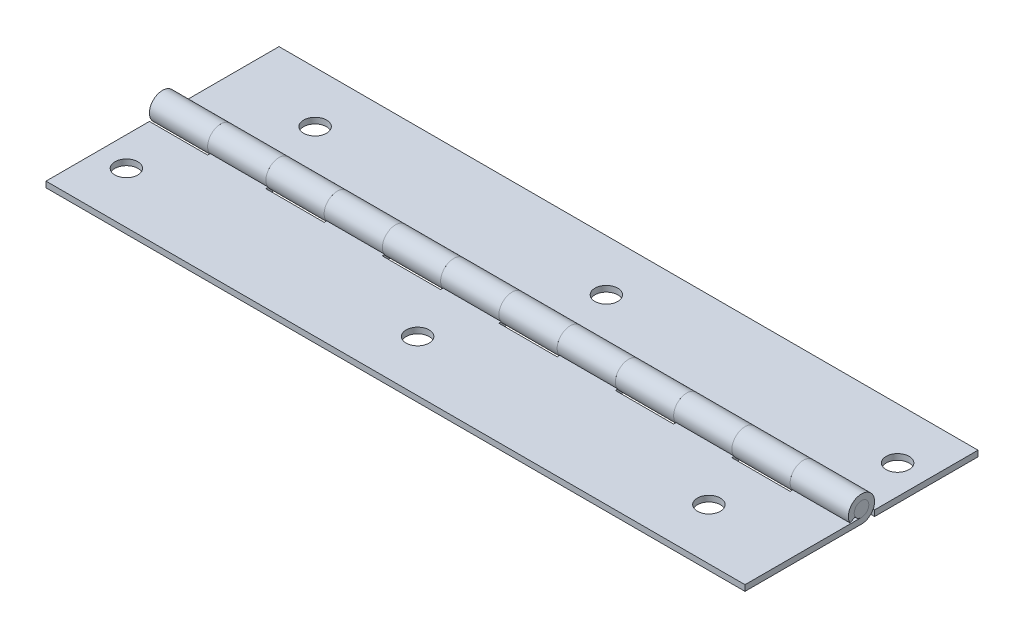
from build123d import *

# Parameters (mm, degrees)
LEFT_LEAF_DEPTH         = 76.2
SKETCH2_W               = 12.7
SKETCH2_H               = 5.715
CUT_EXTRUDE1_DEPTH      = 3.8575
CUT_EXTRUDE1_DEPTH_BACK = 3.8575
RIGHT_LEAF_DEPTH        = 76.2
SKETCH9_W               = 12.7
SKETCH9_H               = 5.715
CUT_EXTRUDE2_DEPTH      = 3.8575
CUT_EXTRUDE2_DEPTH_BACK = 3.8575
SKETCH10_R              = 1.5875
EXTRUDE1_DEPTH          = 76.2
SKETCH11_R              = 2.5019
CUT_EXTRUDE3_DEPTH      = 2.27


with BuildPart() as part:
    # Sketch1 → Left Leaf (new body, symmetric)
    with BuildSketch(Plane(origin=(0, 0, 0), x_dir=(0, 0, -1), z_dir=(1, 0, 0))):
        with BuildLine():
            Line((0, -1.5875), (-25.4, -1.5875))
            Line((-25.4, -1.5875), (-25.4, -2.8575))
            Line((-25.4, -2.8575), (0, -2.8575))
            ThreePointArc((0, -2.8575), (1.449117488, 2.462796125), (-2.497904417, -1.387724676))
            Line((-2.497904417, -1.387724676), (-1.387724676, -0.770958153))
            ThreePointArc((-1.387724676, -0.770958153), (0.805065271, 1.36822007), (0, -1.5875))
        make_face()
    extrude(amount=LEFT_LEAF_DEPTH, both=True)

    # Sketch2 → Cut-Extrude1 (cut, two sides)
    with BuildSketch(Plane(origin=(0, 0, 0), x_dir=(1, 0, 0), z_dir=(0, 1, 0))) as cut_extrude1_sk:
        with Locations((-44.45, 0)):
            Rectangle(SKETCH2_W, SKETCH2_H)
        with Locations((-69.85, 0)):
            Rectangle(SKETCH2_W, SKETCH2_H)
        with Locations((57.15, 0)):
            Rectangle(SKETCH2_W, SKETCH2_H)
        with Locations((-19.05, 0)):
            Rectangle(SKETCH2_W, SKETCH2_H)
        with Locations((6.35, 0)):
            Rectangle(SKETCH2_W, SKETCH2_H)
        with Locations((31.75, 0)):
            Rectangle(SKETCH2_W, SKETCH2_H)
    extrude(amount=CUT_EXTRUDE1_DEPTH, mode=Mode.SUBTRACT)
    extrude(cut_extrude1_sk.sketch, amount=-CUT_EXTRUDE1_DEPTH_BACK, mode=Mode.SUBTRACT)


with BuildPart() as body_2:
    # Sketch3 → Right Leaf (new body, symmetric)
    with BuildSketch(Plane(origin=(0, 0, 0), x_dir=(0, 0, -1), z_dir=(1, 0, 0))):
        with BuildLine():
            Line((25.4, -1.5875), (25.4, -2.8575))
            Line((25.4, -2.8575), (0, -2.8575))
            ThreePointArc((0, -2.8575), (-1.449117488, 2.462796125), (2.497904417, -1.387724676))
            Line((2.497904417, -1.387724676), (1.387724676, -0.770958153))
            ThreePointArc((1.387724676, -0.770958153), (-0.805065271, 1.36822007), (0, -1.5875))
            Line((0, -1.5875), (25.4, -1.5875))
        make_face()
    extrude(amount=RIGHT_LEAF_DEPTH, both=True)

    # Sketch9 → Cut-Extrude2 (cut, two sides)
    with BuildSketch(Plane(origin=(0, 0, 0), x_dir=(1, 0, 0), z_dir=(0, 1, 0))) as cut_extrude2_sk:
        with Locations((-57.15, 0)):
            Rectangle(SKETCH9_W, SKETCH9_H)
        with Locations((-31.75, 0)):
            Rectangle(SKETCH9_W, SKETCH9_H)
        with Locations((-6.35, 0)):
            Rectangle(SKETCH9_W, SKETCH9_H)
        with Locations((19.05, 0)):
            Rectangle(SKETCH9_W, SKETCH9_H)
        with Locations((44.45, 0)):
            Rectangle(SKETCH9_W, SKETCH9_H)
        with Locations((69.85, 0)):
            Rectangle(SKETCH9_W, SKETCH9_H)
    extrude(amount=CUT_EXTRUDE2_DEPTH, mode=Mode.SUBTRACT)
    extrude(cut_extrude2_sk.sketch, amount=-CUT_EXTRUDE2_DEPTH_BACK, mode=Mode.SUBTRACT)


with BuildPart() as body_3:
    # Sketch10 → Extrude1 (new body, symmetric)
    with BuildSketch(Plane(origin=(0, 0, 0), x_dir=(0, 0, -1), z_dir=(1, 0, 0))):
        Circle(SKETCH10_R)
    extrude(amount=EXTRUDE1_DEPTH, both=True)


with BuildPart() as cut_extrude3_tool:
    # Sketch11 → Cut-Extrude3 (new body, through all)
    with BuildSketch(Plane(origin=(0, -1.5875, 0), x_dir=(-1, 0, 0), z_dir=(0, 1, 0))):
        with Locations((-69.85, -14.224)):
            Circle(SKETCH11_R)
        with Locations((-57.15, 14.224)):
            Circle(SKETCH11_R)
        with Locations((-6.35, -14.224)):
            Circle(SKETCH11_R)
        with Locations((6.35, 14.224)):
            Circle(SKETCH11_R)
        with Locations((69.85, 14.224)):
            Circle(SKETCH11_R)
        with Locations((57.15, -14.224)):
            Circle(SKETCH11_R)
    extrude(amount=-CUT_EXTRUDE3_DEPTH)


with BuildPart() as part_1:
    add(part.part)

    # Cut-Extrude3: cut by cut_extrude3_tool
    add(cut_extrude3_tool.part, mode=Mode.SUBTRACT)


with BuildPart() as body_2_1:
    add(body_2.part)

    # Cut-Extrude3: cut by cut_extrude3_tool
    add(cut_extrude3_tool.part, mode=Mode.SUBTRACT)


solid = Compound([body_3.part, part_1.part, body_2_1.part])
